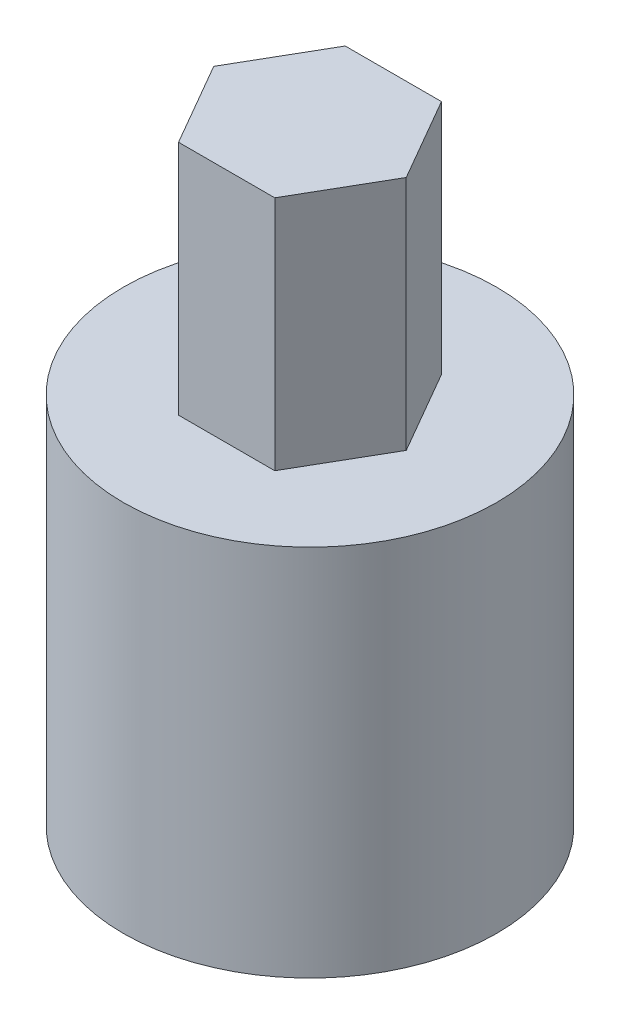
from build123d import *

# Parameters (mm, degrees)
SKETCH1_R           = 7.5
BOSS_EXTRUDE1_DEPTH = 15
BOSS_EXTRUDE2_DEPTH = 9.5
CUT_EXTRUDE1_DEPTH  = 12


with BuildPart() as part:
    # Sketch1 → Boss-Extrude1 (new body)
    with BuildSketch(Plane(origin=(0, 0, 0), x_dir=(1, 0, 0), z_dir=(0, 1, 0))):
        Circle(SKETCH1_R)
    extrude(amount=BOSS_EXTRUDE1_DEPTH)

    # Sketch4 → Boss-Extrude2 (add)
    with BuildSketch(Plane(origin=(0, 15, 0), x_dir=(1, 0, 0), z_dir=(0, 1, 0))):
        Polygon((1.934123402, 3.35), (-1.934123402, 3.35), (-3.868246804, 0), (-1.934123402, -3.35), (1.934123402, -3.35), (3.868246804, 0), align=None)
    extrude(amount=BOSS_EXTRUDE2_DEPTH)

    # Sketch5 → Cut-Extrude1 (cut)
    with BuildSketch(Plane.XZ):
        with BuildLine():
            Line((1.696172161, 2.627), (-1.696172161, 2.627))
            ThreePointArc((-1.696172161, 2.627), (-1.495693594, -2.74609353), (3.127, 0))
            ThreePointArc((3.127, 0), (2.74609353, 1.495693594), (1.696172161, 2.627))
        make_face()
    extrude(amount=-CUT_EXTRUDE1_DEPTH, mode=Mode.SUBTRACT)


solid = part.part
